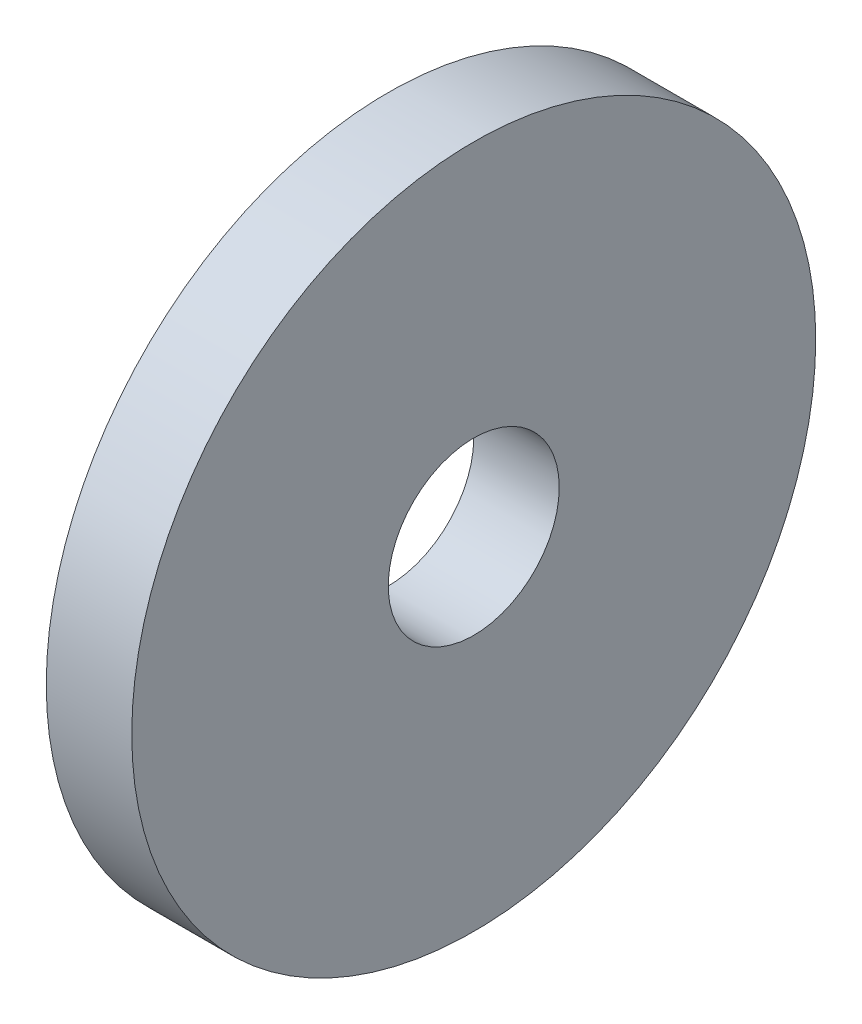
from build123d import *

# Parameters (mm, degrees)
SKETCH1_R               = 12
BOSS_EXTRUDE1_DEPTH     = 3
SKETCH2_R               = 3
CUT_EXTRUDE1_DEPTH      = 1
CUT_EXTRUDE1_DEPTH_BACK = 4


with BuildPart() as part:
    # Sketch1 → Boss-Extrude1 (new body)
    with BuildSketch(Plane(origin=(0, 0, 0), x_dir=(0, 0, -1), z_dir=(1, 0, 0))):
        Circle(SKETCH1_R)
    extrude(amount=BOSS_EXTRUDE1_DEPTH)

    # Sketch2 → Cut-Extrude1 (cut, two sides)
    with BuildSketch(Plane(origin=(3, 0, 0), x_dir=(0, 0, -1), z_dir=(1, 0, 0))) as cut_extrude1_sk:
        Circle(SKETCH2_R)
    extrude(amount=CUT_EXTRUDE1_DEPTH, mode=Mode.SUBTRACT)
    extrude(cut_extrude1_sk.sketch, amount=-CUT_EXTRUDE1_DEPTH_BACK, mode=Mode.SUBTRACT)


solid = part.part
